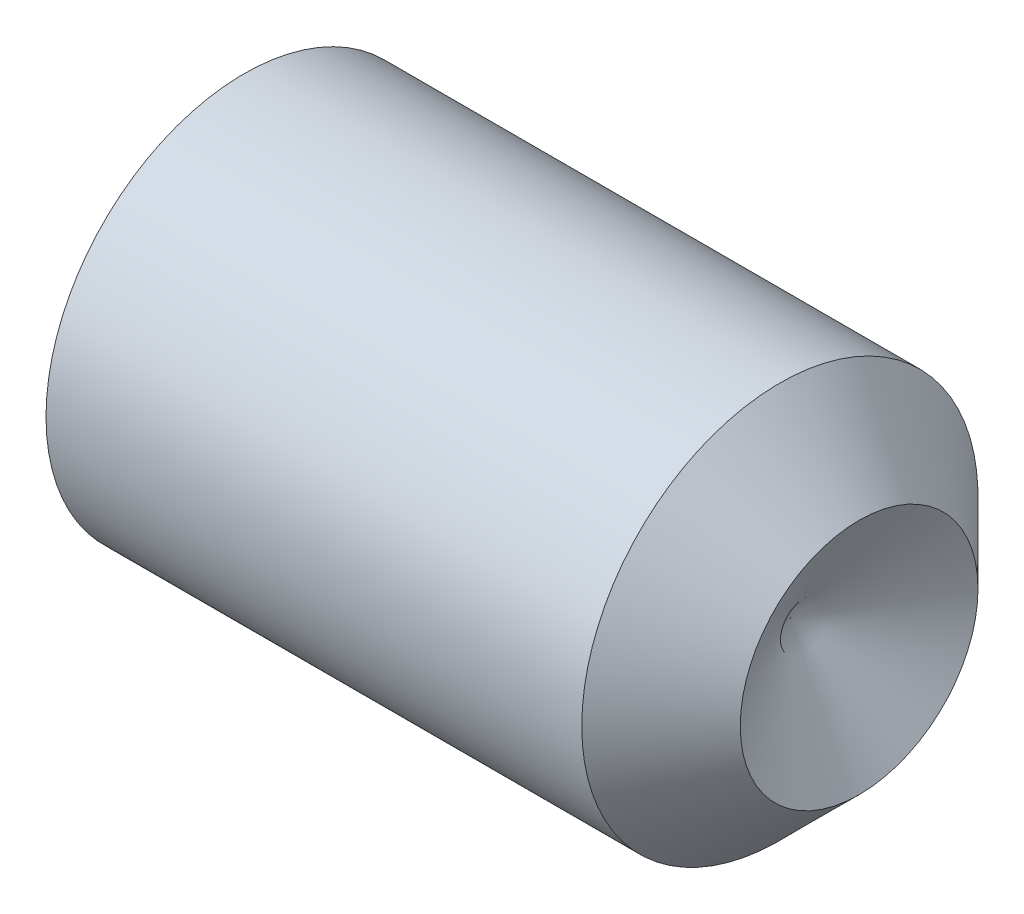
from build123d import *

# Parameters (mm, degrees)
HEX_2_DEPTH = 6


with BuildPart() as part:
    # BodySke → BaseBody (revolve)
    with BuildSketch(Plane.XY):
        Polygon((0, 0), (0, 4.172), (0.478046023, 5), (14, 5), (16, 3), (14.267949192, 0), align=None)
    revolve(axis=Axis((-12.7, 0, 0), (1, 0, 0)))

    # Sketch2 → Hex 2 (cut)
    with BuildSketch(Plane.ZY):
        Polygon((1.443375673, 2.5), (-1.443375673, 2.5), (-2.886751346, 0), (-1.443375673, -2.5), (1.443375673, -2.5), (2.886751346, 0), align=None)
    extrude(amount=-HEX_2_DEPTH, mode=Mode.SUBTRACT)


solid = part.part
